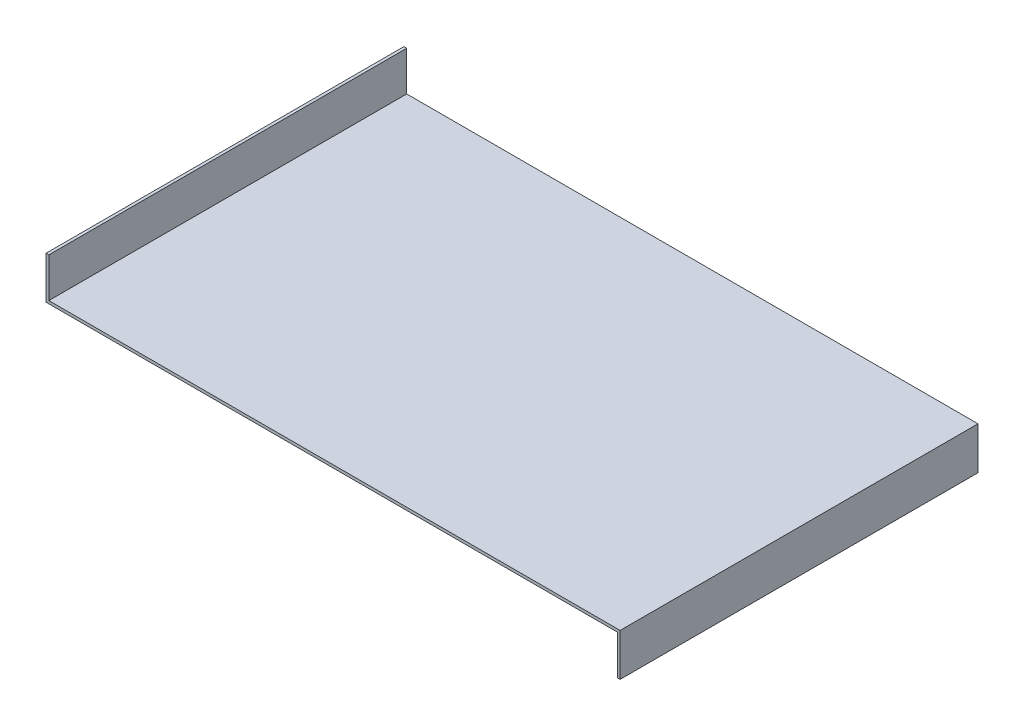
from build123d import *

# Parameters (mm, degrees)
DODANIE_WYCI_GNI_CIE1_DEPTH = 126.55


with BuildPart() as part:
    # Szkic1 → Dodanie-wyciągnięcie1 (new body)
    with BuildSketch(Plane.XY):
        Polygon((0, 0), (0, 15), (-202, 15), (-202, 29), (-203, 29), (-203, 14), (-1, 14), (-1, 0), align=None)
    extrude(amount=DODANIE_WYCI_GNI_CIE1_DEPTH)


solid = part.part
